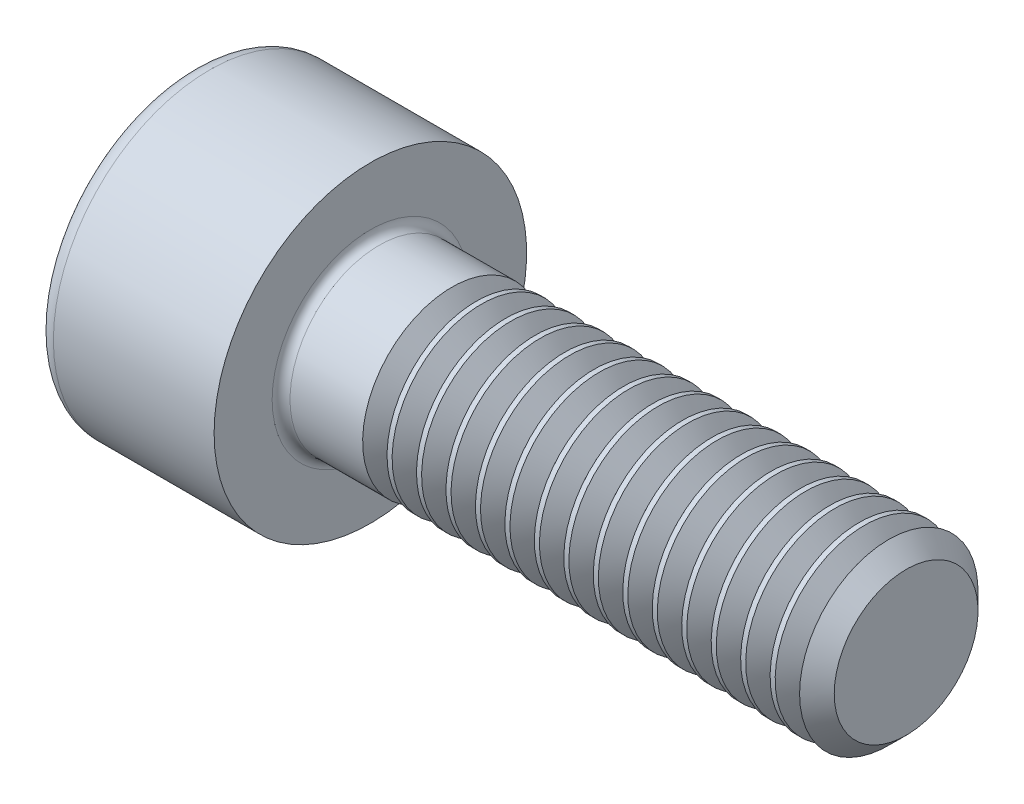
from build123d import *

# Parameters (mm, degrees)
FILLET1_R       = 0.2
FILLET2_R       = 0.4
HEX_2_DEPTH     = 2
THDSCHPAT_COUNT = 15
THDSCHPAT_PITCH = 0.66


with BuildPart() as part:
    # BodySke → Base-Revolve (revolve)
    with BuildSketch(Plane.XY, mode=Mode.PRIVATE) as base_revolve_sk:
        Polygon((0, 0), (0, 3.5), (4, 3.5), (4, 2), (15.61, 2), (16, 1.61), (16, 0), align=None)
    revolve(base_revolve_sk.sketch.rotate(Axis((-31.75, 0, 0), (1, 0, 0)), 90), axis=Axis((-31.75, 0, 0), (1, 0, 0)))  # turned: the seam where the file's is

    # Fillet1
    fillet1_edges = [part.edges().sort_by_distance(p)[0] for p in [
        (4, 0, -2),
    ]]
    fillet(fillet1_edges, radius=FILLET1_R)

    # Fillet2
    fillet2_edges = [part.edges().sort_by_distance(p)[0] for p in [
        (0, 0, -3.5),
    ]]
    fillet(fillet2_edges, radius=FILLET2_R)

    # Sketch2 → Hex-PreBroach (revolve, cut)
    with BuildSketch(Plane.XY, mode=Mode.PRIVATE) as hex_prebroach_sk:
        Polygon((0, 1.51), (2, 1.51), (2.871798906, 0), (0, 0), align=None)
    revolve(hex_prebroach_sk.sketch.rotate(Axis((0, 0, 0), (1, 0, 0)), 90), axis=Axis((0, 0, 0), (1, 0, 0)), mode=Mode.SUBTRACT)  # turned: the seam where the file's is

    # Sketch3 → Hex 2 (cut)
    with BuildSketch(Plane(origin=(0, 0, 0), x_dir=(0, 0.5, 0.866025404), z_dir=(-1, 0, 0))):
        Polygon((0.871798906, 1.51), (-0.871798906, 1.51), (-1.743597813, 0), (-0.871798906, -1.51), (0.871798906, -1.51), (1.743597813, 0), align=None)
    extrude(amount=-HEX_2_DEPTH, mode=Mode.SUBTRACT)

    # ThdSchSke → ThreadSchematic (revolve, cut)
    with BuildSketch(Plane.XY, mode=Mode.PRIVATE) as threadschematic_sk:
        Polygon((6.1, -1.61), (5.82691906, -2), (5.82691906, -2.5), (6.37308094, -2.5), (6.37308094, -2), align=None)
    threadschematic = revolve(threadschematic_sk.sketch.rotate(Axis((-3.175, 0, 0), (1, 0, 0)), 270), axis=Axis((-3.175, 0, 0), (1, 0, 0)), mode=Mode.SUBTRACT)  # turned: the seam where the file's is

    # ThdSchPat: ThreadSchematic ×15
    with Locations(*[(i * THDSCHPAT_PITCH, 0, 0) for i in range(1, THDSCHPAT_COUNT)]):
        add(threadschematic, mode=Mode.SUBTRACT)


solid = part.part
